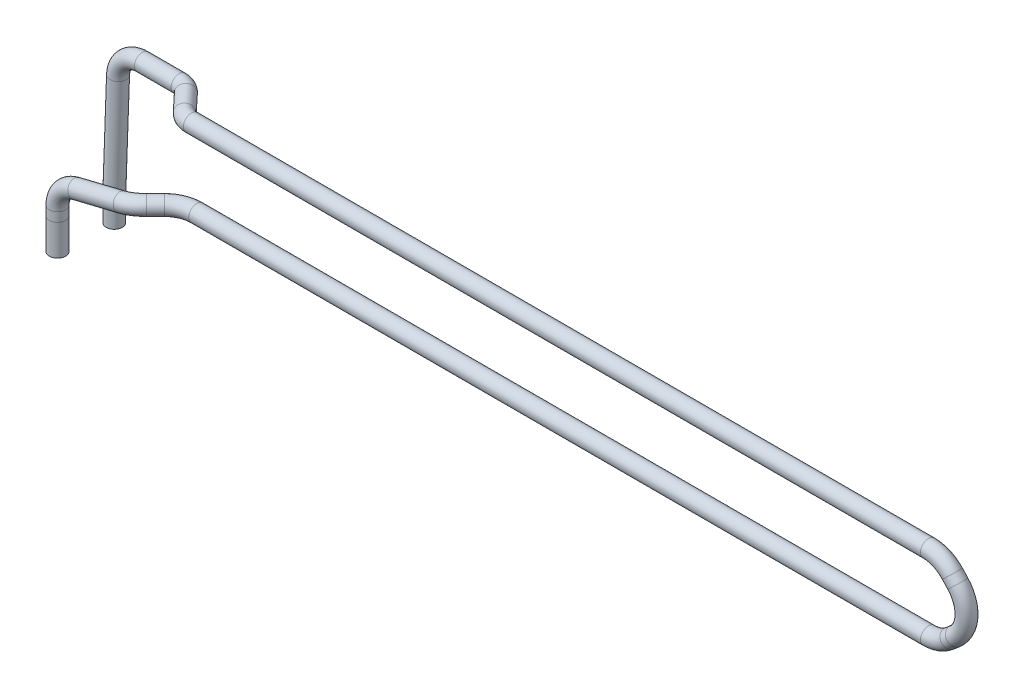
from build123d import *

# Parameters (mm, degrees)
SWEEP1_PROFILE_R = 1


with BuildPart() as part:
    # Sweep1: sweep along a curve in space
    with BuildLine() as sweep1_path:
        Line((-62.090612365, -10.590919014, 3.446712504), (-62.090612365, -14.401731911, 3.446712504))
        Line((-62.090612365, -9.4553548, 3.446712504), (-62.090612365, -10.590919014, 3.446712504))
        ThreePointArc((-62.090612365, -9.4553548, 3.446712504), (-61.449636995, -7.601978747, 3.446712504), (-59.800610502, -6.540581628, 3.446712504))
        Line((-54.195074798, -5.175151224, 3.446712504), (-59.800610502, -6.540581628, 3.446712504))
        ThreePointArc((-52.025907271, -4.86933782, 2.533008422), (-53.028684132, -4.949042, 3.208573711), (-54.195074798, -5.175151224, 3.446712504))
        Line((-52.025907271, -4.86933782, 2.533008422), (-50.944041501, -4.86933782, 1.451142652))
        ThreePointArc((-50.944041501, -4.86933782, 1.451142652), (-49.646348105, -4.86933782, 0.584051647), (-48.115614376, -4.86933782, 0.279569777))
        Line((-48.115614376, -4.86933782, 0.279569777), (41.891910563, -4.86933782, 0.279569777))
        ThreePointArc((41.891910563, -4.86933782, 0.279569777), (43.279021203, -4.621127269, 0.279569777), (44.493984095, -3.907299856, 0.279569777))
        Line((44.493984095, -3.907299856, 0.279569777), (45.170290578, -3.328030209, 0.279569777))
        ThreePointArc((45.170290578, -3.328030209, 0.279569777), (46.561713678, -0.518069604, 0.279569777), (45.49914886, 2.431996981, 0.279569777))
        Line((45.49914886, 2.431996981, 0.279569777), (44.822842377, 3.160197107, 0.279569777))
        ThreePointArc((41.891910563, 4.438131953, 0.279569777), (43.490619321, 4.104755782, 0.279569777), (44.822842377, 3.160197107, 0.279569777))
        Line((41.891910563, 4.438131953, 0.279569777), (-48.775947923, 4.438131953, 0.279569777))
        ThreePointArc((-48.775947923, 4.438131953, 0.279569777), (-49.572047381, 4.438131953, 0.114297455), (-50.236573634, 4.438131953, -0.35420457))
        Line((-50.236573634, 4.438131953, -0.35420457), (-52.269592885, 4.438131953, -2.527696321))
        ThreePointArc((-53.730218595, 4.438131953, -3.161470668), (-52.934119137, 4.438131953, -2.996198346), (-52.269592885, 4.438131953, -2.527696321))
        Line((-53.730218595, 4.438131953, -3.161470668), (-58.252246271, 4.438131953, -3.161470668))
        ThreePointArc((-61.250344312, 1.544940827, -3.161470668), (-60.33546174, 3.596884674, -3.161470668), (-58.252246271, 4.438131953, -3.161470668))
        Line((-61.250344312, 1.544940827, -3.161470668), (-61.717378375, -11.56458697, -3.161470668))
        Line((-61.717378375, -11.56458697, -3.161470668), (-61.717378375, -14.449513465, -3.161470668))
    # Sweep1 profile (on start of the path) → Sweep1 (sweep)
    with BuildSketch(Plane(origin=(-61.717378375, -14.449513465, -3.161470668), x_dir=(0, 0, 1), z_dir=(0, 1, 0))):
        Circle(SWEEP1_PROFILE_R)
    sweep(path=sweep1_path.line, transition=Transition.RIGHT)


solid = part.part
